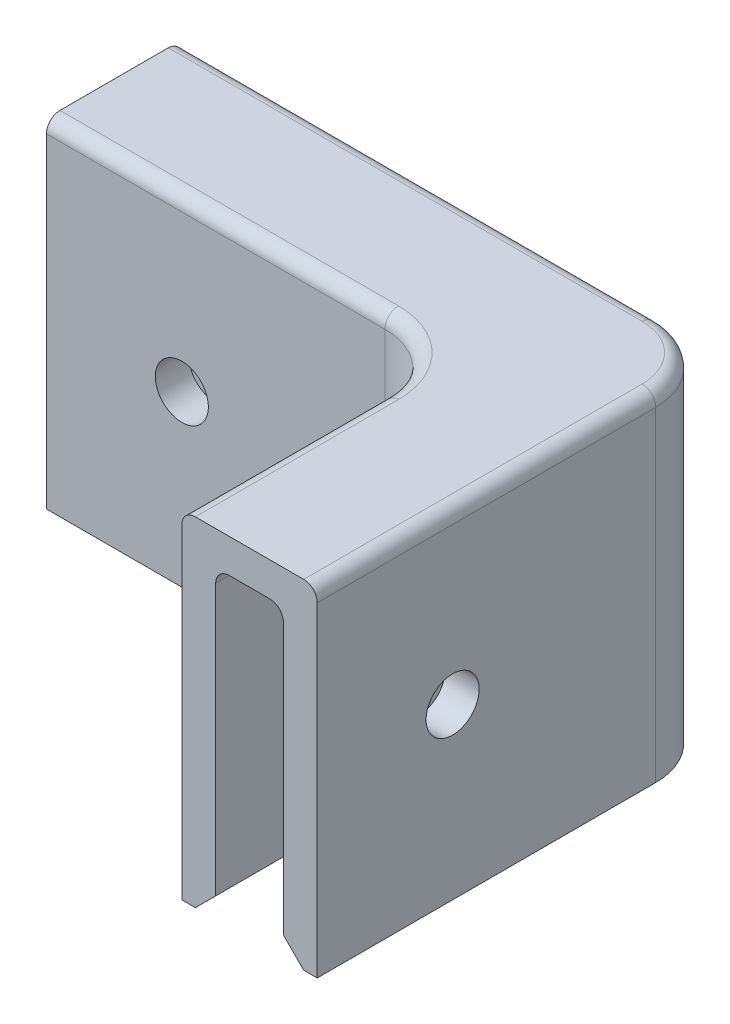
from build123d import *

# Parameters (mm, degrees)
BOSS_EXTRUDE1_DEPTH        = 31.75
FILLET1_R                  = 6.35
SHELL1_T                   = -3.175
F_9_0_196_DIAMETER_HOLE1_D = 4.9784
F_9_0_196_DIAMETER_HOLE2_D = 4.9784
CHAMFER1_SIZE              = 1.905
FILLET2_R                  = 1.27


with BuildPart() as part:
    # Sketch1 → Boss-Extrude1 (new body)
    with BuildSketch(Plane(origin=(0, 0, 0), x_dir=(1, 0, 0), z_dir=(0, 1, 0))):
        Polygon((0, 0), (0, -38.1), (-12.7, -38.1), (-12.7, -12.7), (-50.8, -12.7), (-50.8, 0), align=None)
    extrude(amount=BOSS_EXTRUDE1_DEPTH)

    # Fillet1
    fillet1_edges = [part.edges().sort_by_distance(p)[0] for p in [
        (0, 15.875, 0),
        (-12.7, 15.875, 12.7),
    ]]
    fillet(fillet1_edges, radius=FILLET1_R)

    # Shell1
    shell1_openings = [part.faces().sort_by_distance(p)[0] for p in [
        (-6.35, 15.875, 38.1),
        (-50.8, 15.875, 6.35),
        (-18.721217985, 0, 15.546217985),
    ]]
    offset(amount=SHELL1_T, openings=shell1_openings, kind=Kind.INTERSECTION)

    # #9 (0.196) Diameter Hole1 (through all)
    with Locations(Plane.ZY.offset(12.7)):
        with Locations((25.4, 15.875)):
            Hole(F_9_0_196_DIAMETER_HOLE1_D / 2)

    # #9 (0.196) Diameter Hole2 (through all)
    with Locations(Plane.XY.offset(12.7)):
        with Locations((-38.1, 15.875)):
            Hole(F_9_0_196_DIAMETER_HOLE2_D / 2)

    # Chamfer1
    chamfer1_edges = [part.edges().sort_by_distance(p)[0] for p in [
        (-28.575, 0, 3.175),
        (-34.925, 0, 9.525),
        (-9.525, 0, 28.575),
        (-3.175, 0, 22.225),
        (-4.10493597, 0, 4.10493597),
        (-12.314807909, 0, 12.314807909),
    ]]
    chamfer(chamfer1_edges, length=CHAMFER1_SIZE)

    # Fillet2
    fillet2_edges = [part.edges().sort_by_distance(p)[0] for p in [
        (-34.925, 31.75, 12.7),
        (-28.575, 31.75, 0),
        (-12.7, 31.75, 28.575),
        (-1.859871939, 31.75, 1.859871939),
        (0, 31.75, 22.225),
        (-14.559871939, 31.75, 14.559871939),
        (-3.175, 28.575, 22.225),
        (-4.10493597, 28.575, 4.10493597),
        (-28.575, 28.575, 3.175),
        (-34.925, 28.575, 9.525),
        (-12.314807909, 28.575, 12.314807909),
        (-9.525, 28.575, 28.575),
    ]]
    fillet(fillet2_edges, radius=FILLET2_R)


solid = part.part
